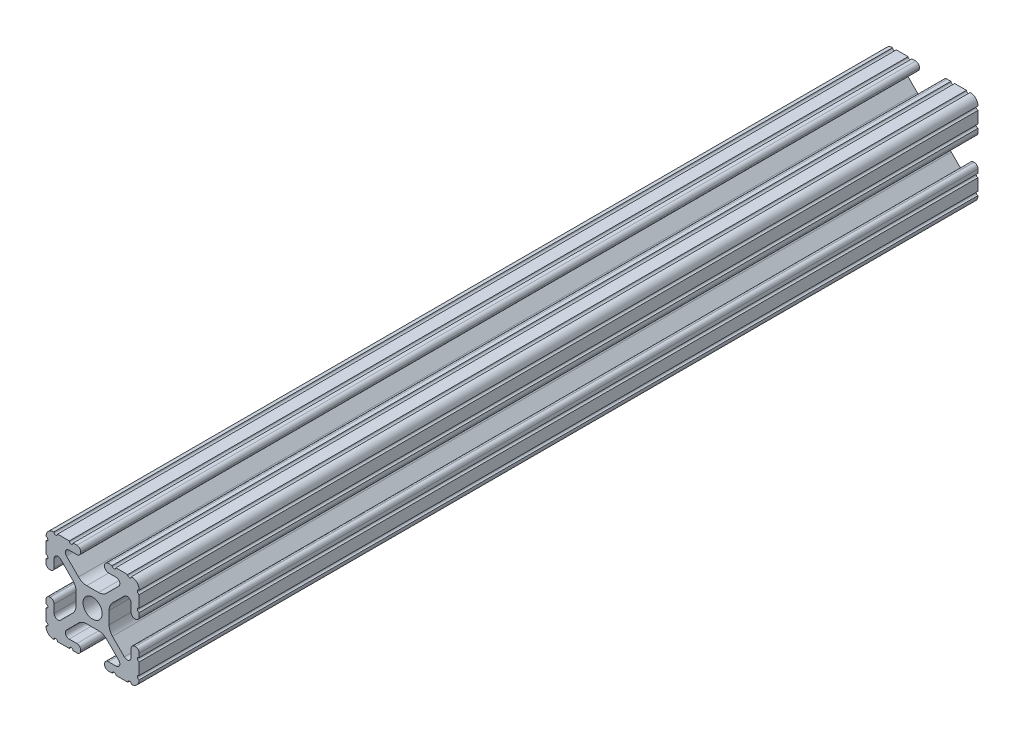
from build123d import *

# Parameters (mm, degrees)
SKETCH1_R           = 2.6035
BOSS_EXTRUDE1_DEPTH = 114.3


with BuildPart() as part:
    # Sketch1 → Boss-Extrude1 (new body, symmetric)
    with BuildSketch(Plane(origin=(0, 0, 0), x_dir=(0, 1, 0), z_dir=(0, 0, 1))):
        with BuildLine():
            Line((6.333126718, -12.7), (9.550443118, -12.7))
            ThreePointArc((9.550443118, -12.7), (10.058366869, -12.192000006), (10.566443095, -12.699847501))
            ThreePointArc((10.566443095, -12.699847501), (12.082537762, -12.08250727), (12.699846982, -10.566399977))
            ThreePointArc((12.699846982, -10.566399977), (12.192000006, -10.058323491), (12.7, -9.5504))
            Line((12.7, -9.5504), (12.7, -6.3330836))
            ThreePointArc((12.7, -6.3330836), (12.192, -5.8250836), (12.7, -5.3170836))
            Line((12.7, -5.3170836), (12.7, -4.287469289))
            ThreePointArc((12.7, -4.287469289), (12.39275138, -3.545705502), (11.650987593, -3.238456882))
            Line((11.650987593, -3.238456882), (11.539212407, -3.238456882))
            ThreePointArc((11.539212407, -3.238456882), (10.79744862, -3.545705502), (10.4902, -4.287469289))
            Line((10.4902, -4.287469289), (10.4902, -6.402089023))
            ThreePointArc((10.4902, -6.402089023), (9.856505071, -7.351067942), (8.737131347, -7.129408934))
            Line((8.737131347, -7.129408934), (5.441005833, -3.840816462))
            ThreePointArc((5.441005833, -3.840816462), (4.750877967, -2.809883091), (4.5085, -1.593185507))
            Line((4.5085, -1.593185507), (4.5085, 1.593185507))
            ThreePointArc((4.5085, 1.593185507), (4.750877967, 2.809883091), (5.441005833, 3.840816462))
            Line((5.441005833, 3.840816462), (8.737131347, 7.129408934))
            ThreePointArc((8.737131347, 7.129408934), (9.856505071, 7.351067942), (10.4902, 6.402089023))
            Line((10.4902, 6.402089023), (10.4902, 4.287469289))
            ThreePointArc((10.4902, 4.287469289), (10.79744862, 3.545705502), (11.539212407, 3.238456882))
            Line((11.539212407, 3.238456882), (11.650987593, 3.238456882))
            ThreePointArc((11.650987593, 3.238456882), (12.39275138, 3.545705502), (12.7, 4.287469289))
            Line((12.7, 4.287469289), (12.7, 5.3170836))
            ThreePointArc((12.7, 5.3170836), (12.192, 5.8250836), (12.7, 6.3330836))
            Line((12.7, 6.3330836), (12.7, 9.5504))
            ThreePointArc((12.7, 9.5504), (12.192000006, 10.058323491), (12.699846982, 10.566399977))
            ThreePointArc((12.699846982, 10.566399977), (12.082537762, 12.08250727), (10.566443095, 12.699847501))
            ThreePointArc((10.566443095, 12.699847501), (10.058366869, 12.192000006), (9.550443118, 12.7))
            Line((9.550443118, 12.7), (6.333126718, 12.7))
            ThreePointArc((6.333126718, 12.7), (5.825126718, 12.192), (5.317126718, 12.7))
            Line((5.317126718, 12.7), (4.287512407, 12.7))
            ThreePointArc((4.287512407, 12.7), (3.54574862, 12.39275138), (3.2385, 11.650987593))
            Line((3.2385, 11.650987593), (3.2385, 11.539212407))
            ThreePointArc((3.2385, 11.539212407), (3.54574862, 10.79744862), (4.287512407, 10.4902))
            Line((4.287512407, 10.4902), (6.476788598, 10.4902))
            ThreePointArc((6.476788598, 10.4902), (7.432222385, 9.85140422), (7.207036008, 8.724370562))
            Line((7.207036008, 8.724370562), (3.898272566, 5.423169045))
            ThreePointArc((3.898272566, 5.423169045), (2.869120213, 4.736787962), (1.655778399, 4.4958))
            Line((1.655778399, 4.4958), (-1.655778399, 4.4958))
            ThreePointArc((-1.655778399, 4.4958), (-2.869120213, 4.736787962), (-3.898272566, 5.423169045))
            Line((-3.898272566, 5.423169045), (-7.207036008, 8.724370562))
            ThreePointArc((-7.207036008, 8.724370562), (-7.432222385, 9.85140422), (-6.476788598, 10.4902))
            Line((-6.476788598, 10.4902), (-4.287512407, 10.4902))
            ThreePointArc((-4.287512407, 10.4902), (-3.54574862, 10.79744862), (-3.2385, 11.539212407))
            Line((-3.2385, 11.539212407), (-3.2385, 11.650987593))
            ThreePointArc((-3.2385, 11.650987593), (-3.54574862, 12.39275138), (-4.287512407, 12.7))
            Line((-4.287512407, 12.7), (-5.317126718, 12.7))
            ThreePointArc((-5.317126718, 12.7), (-5.825126718, 12.192), (-6.333126718, 12.7))
            Line((-6.333126718, 12.7), (-9.550443118, 12.7))
            ThreePointArc((-9.550443118, 12.7), (-10.058366869, 12.192000006), (-10.566443095, 12.699847501))
            ThreePointArc((-10.566443095, 12.699847501), (-12.082537762, 12.08250727), (-12.699846982, 10.566399977))
            ThreePointArc((-12.699846982, 10.566399977), (-12.192000006, 10.058323491), (-12.7, 9.5504))
            Line((-12.7, 9.5504), (-12.7, 6.3330836))
            ThreePointArc((-12.7, 6.3330836), (-12.192, 5.8250836), (-12.7, 5.3170836))
            Line((-12.7, 5.3170836), (-12.7, 4.287469289))
            ThreePointArc((-12.7, 4.287469289), (-12.39275138, 3.545705502), (-11.650987593, 3.238456882))
            Line((-11.650987593, 3.238456882), (-11.539212407, 3.238456882))
            ThreePointArc((-11.539212407, 3.238456882), (-10.79744862, 3.545705502), (-10.4902, 4.287469289))
            Line((-10.4902, 4.287469289), (-10.4902, 6.402089023))
            ThreePointArc((-10.4902, 6.402089023), (-9.856505071, 7.351067942), (-8.737131347, 7.129408934))
            Line((-8.737131347, 7.129408934), (-5.441005833, 3.840816462))
            ThreePointArc((-5.441005833, 3.840816462), (-4.750877967, 2.809883091), (-4.5085, 1.593185507))
            Line((-4.5085, 1.593185507), (-4.5085, -1.593185507))
            ThreePointArc((-4.5085, -1.593185507), (-4.750877967, -2.809883091), (-5.441005833, -3.840816462))
            Line((-5.441005833, -3.840816462), (-8.737131347, -7.129408934))
            ThreePointArc((-8.737131347, -7.129408934), (-9.856505071, -7.351067942), (-10.4902, -6.402089023))
            Line((-10.4902, -6.402089023), (-10.4902, -4.287469289))
            ThreePointArc((-10.4902, -4.287469289), (-10.79744862, -3.545705502), (-11.539212407, -3.238456882))
            Line((-11.539212407, -3.238456882), (-11.650987593, -3.238456882))
            ThreePointArc((-11.650987593, -3.238456882), (-12.39275138, -3.545705502), (-12.7, -4.287469289))
            Line((-12.7, -4.287469289), (-12.7, -5.3170836))
            ThreePointArc((-12.7, -5.3170836), (-12.192, -5.8250836), (-12.7, -6.3330836))
            Line((-12.7, -6.3330836), (-12.7, -9.5504))
            ThreePointArc((-12.7, -9.5504), (-12.192000006, -10.058323491), (-12.699846982, -10.566399977))
            ThreePointArc((-12.699846982, -10.566399977), (-12.082537762, -12.08250727), (-10.566443095, -12.699847501))
            ThreePointArc((-10.566443095, -12.699847501), (-10.058366869, -12.192000006), (-9.550443118, -12.7))
            Line((-9.550443118, -12.7), (-6.333126718, -12.7))
            ThreePointArc((-6.333126718, -12.7), (-5.825126718, -12.192), (-5.317126718, -12.7))
            Line((-5.317126718, -12.7), (-4.287512407, -12.7))
            ThreePointArc((-4.287512407, -12.7), (-3.54574862, -12.39275138), (-3.2385, -11.650987593))
            Line((-3.2385, -11.650987593), (-3.2385, -11.539212407))
            ThreePointArc((-3.2385, -11.539212407), (-3.54574862, -10.79744862), (-4.287512407, -10.4902))
            Line((-4.287512407, -10.4902), (-6.416408329, -10.4902))
            ThreePointArc((-6.416408329, -10.4902), (-7.41473083, -9.822813117), (-7.179650497, -8.645192506))
            Line((-7.179650497, -8.645192506), (-3.952270251, -5.423690499))
            ThreePointArc((-3.952270251, -5.423690499), (-2.922936451, -4.736929036), (-1.709253557, -4.4958))
            Line((-1.709253557, -4.4958), (1.709253557, -4.4958))
            ThreePointArc((1.709253557, -4.4958), (2.922936451, -4.736929036), (3.952270251, -5.423690499))
            Line((3.952270251, -5.423690499), (7.179650497, -8.645192506))
            ThreePointArc((7.179650497, -8.645192506), (7.41473083, -9.822813117), (6.416408329, -10.4902))
            Line((6.416408329, -10.4902), (4.287512407, -10.4902))
            ThreePointArc((4.287512407, -10.4902), (3.54574862, -10.79744862), (3.2385, -11.539212407))
            Line((3.2385, -11.539212407), (3.2385, -11.650987593))
            ThreePointArc((3.2385, -11.650987593), (3.54574862, -12.39275138), (4.287512407, -12.7))
            Line((4.287512407, -12.7), (5.317126718, -12.7))
            ThreePointArc((5.317126718, -12.7), (5.825126718, -12.192), (6.333126718, -12.7))
        make_face()
        Circle(SKETCH1_R, mode=Mode.SUBTRACT)
    extrude(amount=BOSS_EXTRUDE1_DEPTH, both=True)


solid = part.part
